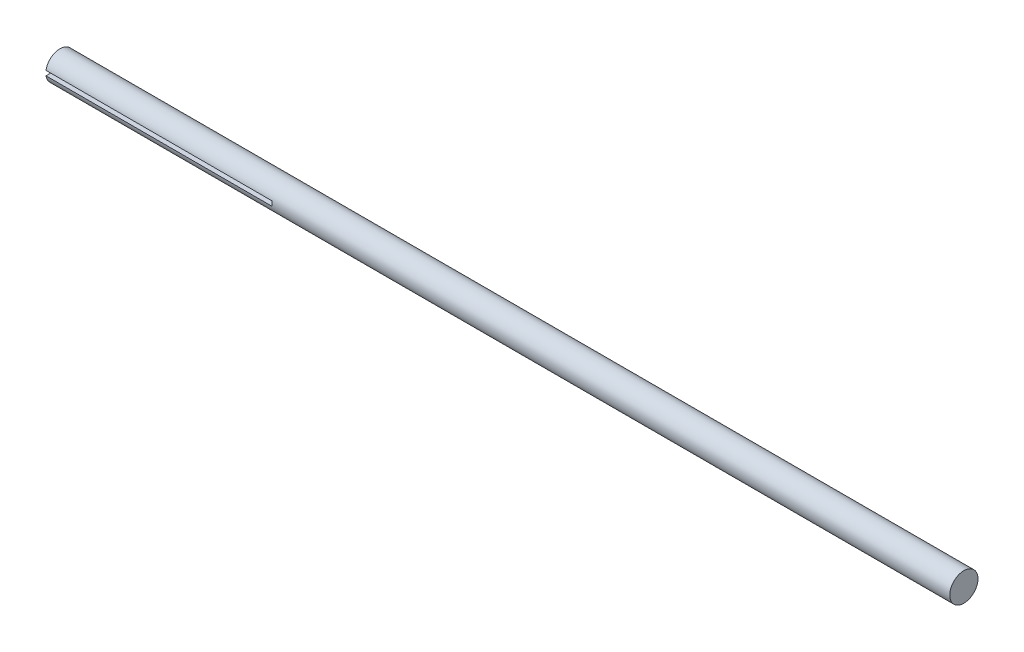
from build123d import *

# Parameters (mm, degrees)
SKETCH1_R           = 4.7625
BOSS_EXTRUDE1_DEPTH = 304.8
SKETCH2_W           = 12.7
SKETCH2_H           = 1.5875
CUT_EXTRUDE1_DEPTH  = 76.2


with BuildPart() as part:
    # Sketch1 → Boss-Extrude1 (new body)
    with BuildSketch(Plane(origin=(0, 0, 0), x_dir=(0, 0, -1), z_dir=(1, 0, 0))):
        Circle(SKETCH1_R)
    extrude(amount=BOSS_EXTRUDE1_DEPTH)

    # Sketch2 → Cut-Extrude1 (cut)
    with BuildSketch(Plane.ZY):
        Rectangle(SKETCH2_W, SKETCH2_H)
    extrude(amount=-CUT_EXTRUDE1_DEPTH, mode=Mode.SUBTRACT)


solid = part.part
